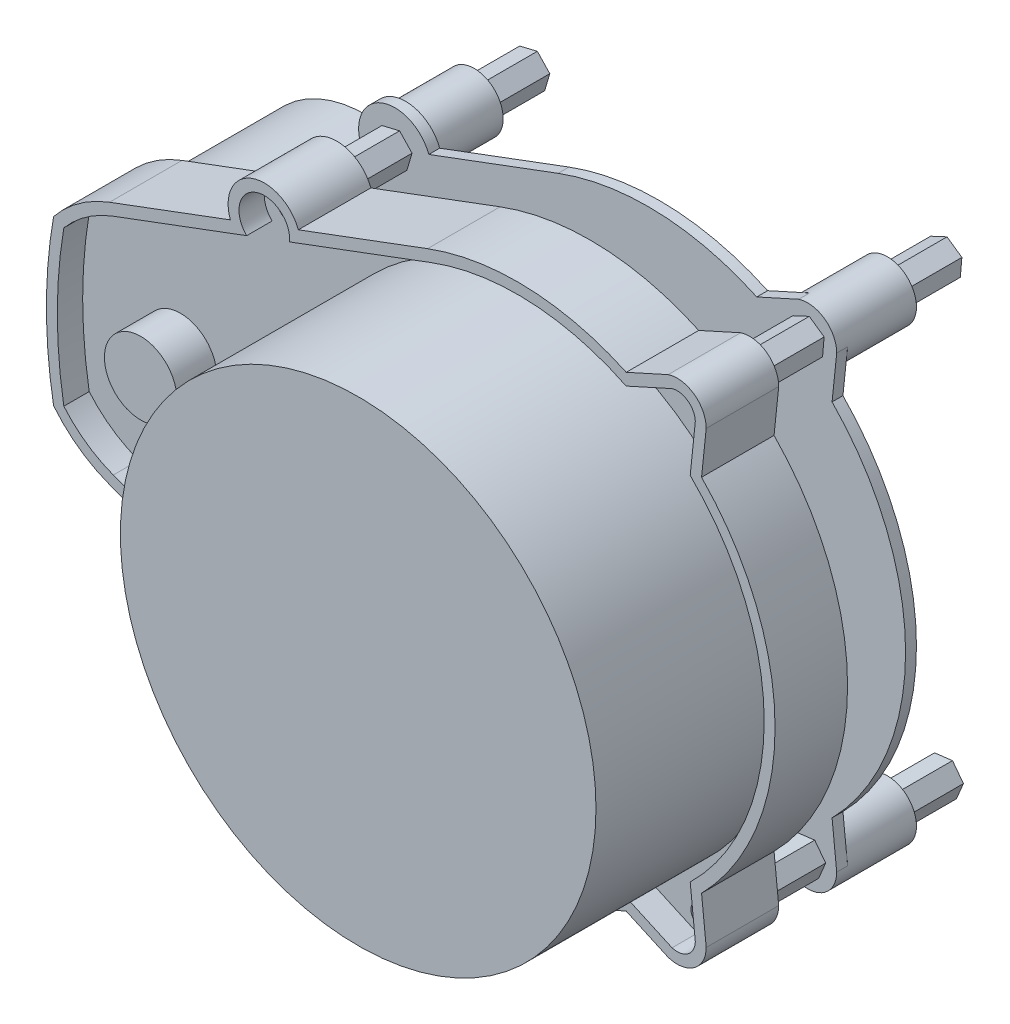
from build123d import *

# Parameters (mm, degrees)
ESQUISSE1_R             = 1.6
BOSS_EXTRU_1_DEPTH      = 10
ESQUISSE2_R             = 32.8
BOSS_EXTRU_2_DEPTH      = 22
ENL_V_MAT_EXTRU_1_DEPTH = 3.5
BOSS_EXTRU_3_REACH      = 12
ESQUISSE4_R             = 32.8
ESQUISSE5_R             = 16
BOSS_EXTRU_4_DEPTH      = 19
ESQUISSE6_R             = 1
BOSS_EXTRU_5_DEPTH      = 27
BOSS_EXTRU_6_DEPTH      = 1.5
ESQUISSE8_R             = 5
BOSS_EXTRU_7_DEPTH      = 5.5
SKETCH2_R               = 4
SKETCH2_R_2             = 3
BOSS_EXTRUDE1_DEPTH     = 9.5


with BuildPart() as part:
    # Esquisse1 → Boss.-Extru.1 (new body)
    with BuildSketch(Plane.XY):
        with BuildLine():
            ThreePointArc((-56.3, -16.861494596), (-60.528670487, -14.599558136), (-64.01, -11.301322931))
            ThreePointArc((-64.01, -11.301322931), (-65, 0), (-64.01, 11.301322931))
            ThreePointArc((-64.01, 11.301322931), (-60.528670487, 14.599558136), (-56.3, 16.861494596))
            Line((-56.3, 16.861494596), (-39.624688626, 23.091930519))
            ThreePointArc((-39.624688626, 23.091930519), (-36.690940127, 29.525679018), (-30.257191628, 26.591930519))
            Line((-30.257191628, 26.591930519), (-12.425, 33.254614341))
            ThreePointArc((-12.425, 33.254614341), (1.381675102, 35.473102119), (14.973963383, 32.187426436))
            Line((14.973963383, 32.187426436), (20.756023105, 34.801647207))
            ThreePointArc((20.756023105, 34.801647207), (24.347774736, 34.238511045), (26, 31))
            Line((26, 31), (25.359978077, 24.841930519))
            ThreePointArc((25.359978077, 24.841930519), (35.5, 0), (25.359978077, -24.841930519))
            Line((25.359978077, -24.841930519), (26, -31))
            ThreePointArc((26, -31), (24.347774736, -34.238511045), (20.756023105, -34.801647207))
            Line((20.756023105, -34.801647207), (14.973963383, -32.187426436))
            ThreePointArc((14.973963383, -32.187426436), (1.381675102, -35.473102119), (-12.425, -33.254614341))
            Line((-12.425, -33.254614341), (-30.257191628, -26.591930519))
            ThreePointArc((-30.257191628, -26.591930519), (-36.690940127, -29.525679018), (-39.624688626, -23.091930519))
            Line((-39.624688626, -23.091930519), (-56.3, -16.861494596))
        make_face()
        with Locations((-35, -25)):
            Circle(ESQUISSE1_R, mode=Mode.SUBTRACT)
        with Locations((22, 31)):
            Circle(ESQUISSE1_R, mode=Mode.SUBTRACT)
        with Locations((-35, 25)):
            Circle(ESQUISSE1_R, mode=Mode.SUBTRACT)
        with Locations((22, -31)):
            Circle(ESQUISSE1_R, mode=Mode.SUBTRACT)
    extrude(amount=BOSS_EXTRU_1_DEPTH)

    # Esquisse2 → Boss.-Extru.2 (add)
    with BuildSketch(Plane.XY.offset(10)):
        Circle(ESQUISSE2_R)
    extrude(amount=BOSS_EXTRU_2_DEPTH)

    # Esquisse3 → Enlèv. mat.-Extru.1 (cut)
    with BuildSketch(Plane.XY.offset(10)):
        with BuildLine():
            Line((-55.775, -15.456370046), (-37.378202776, -22.330008789))
            ThreePointArc((-37.378202776, -22.330008789), (-36.165940127, -28.120554469), (-31.453677478, -24.543603151))
            Line((-31.453677478, -24.543603151), (-11.9, -31.849489792))
            ThreePointArc((-11.9, -31.849489792), (1.664031028, -33.959255009), (14.956816294, -30.533484019))
            Line((14.956816294, -30.533484019), (21.291141631, -33.397398551))
            ThreePointArc((21.291141631, -33.397398551), (23.468656713, -33.023128137), (24.499056843, -31.06866508))
            Line((24.499056843, -31.06866508), (23.79417774, -24.286562245))
            ThreePointArc((23.79417774, -24.286562245), (34, 0), (23.79417774, 24.286562245))
            Line((23.79417774, 24.286562245), (24.499056843, 31.06866508))
            ThreePointArc((24.499056843, 31.06866508), (23.468656713, 33.023128137), (21.291141631, 33.397398551))
            Line((21.291141631, 33.397398551), (14.956816294, 30.533484019))
            ThreePointArc((14.956816294, 30.533484019), (1.664031028, 33.959255009), (-11.9, 31.849489792))
            Line((-11.9, 31.849489792), (-31.453677478, 24.543603151))
            ThreePointArc((-31.453677478, 24.543603151), (-36.165940127, 28.120554469), (-37.378202776, 22.330008789))
            Line((-37.378202776, 22.330008789), (-55.775, 15.456370046))
            ThreePointArc((-55.775, 15.456370046), (-59.496201473, 13.493411636), (-62.6, 10.653168543))
            ThreePointArc((-62.6, 10.653168543), (-63.5, 0), (-62.6, -10.653168543))
            ThreePointArc((-62.6, -10.653168543), (-59.496201473, -13.493411636), (-55.775, -15.456370046))
        make_face()
    extrude(amount=-ENL_V_MAT_EXTRU_1_DEPTH, mode=Mode.SUBTRACT)

    # Esquisse4 → Boss.-Extru.3 (add, up to next)
    with BuildSketch(Plane(origin=(0, 0, 10), x_dir=(-1, 0, 0), z_dir=(0, 0, -1)), mode=Mode.PRIVATE) as boss_extru_3_sk1:
        Circle(ESQUISSE4_R)
    boss_extru_3_tool1 = extrude(boss_extru_3_sk1.sketch, amount=BOSS_EXTRU_3_REACH, mode=Mode.PRIVATE) - part.part
    add(boss_extru_3_tool1.solids().sort_by_distance((0, 0, 10))[0])

    # Esquisse5 → Boss.-Extru.4 (add)
    with BuildSketch(Plane(origin=(0, 0, 0), x_dir=(-1, 0, 0), z_dir=(0, 0, -1))):
        with Locations((50, 0)):
            Circle(ESQUISSE5_R)
    extrude(amount=BOSS_EXTRU_4_DEPTH)

    # Esquisse6 → Boss.-Extru.5 (add)
    with BuildSketch(Plane(origin=(0, 0, 0), x_dir=(-1, 0, 0), z_dir=(0, 0, -1))):
        Polygon((-20.489225606, -29.008126327), (-22.969626005, -28.695694159), (-24.480400399, -30.687567832), (-23.510774394, -32.991873673), (-21.030373995, -33.304305841), (-19.519599601, -31.312432168), align=None)
        with Locations((-22, -31)):
            Circle(ESQUISSE6_R, mode=Mode.SUBTRACT)
        Polygon((36.086835018, -22.748602735), (33.593650283, -22.933074633), (32.506815266, -25.184471898), (33.913164982, -27.251397265), (36.406349717, -27.066925367), (37.493184734, -24.815528102), align=None)
        with Locations((35, -25)):
            Circle(ESQUISSE6_R, mode=Mode.SUBTRACT)
        Polygon((36.720274889, 26.814016072), (34.289153443, 27.396809791), (32.568878555, 25.582793719), (33.279725111, 23.185983928), (35.710846557, 22.603190209), (37.431121445, 24.417206281), align=None)
        with Locations((35, 25)):
            Circle(ESQUISSE6_R, mode=Mode.SUBTRACT)
        Polygon((-19.952160425, 32.43399898), (-22.217959758, 33.490480585), (-24.265799333, 32.056481605), (-24.047839575, 29.56600102), (-21.782040242, 28.509519415), (-19.734200667, 29.943518395), align=None)
        with Locations((-22, 31)):
            Circle(ESQUISSE6_R, mode=Mode.SUBTRACT)
    extrude(amount=BOSS_EXTRU_5_DEPTH)

    # Esquisse7 → Boss.-Extru.6 (add)
    with BuildSketch(Plane(origin=(0, 0, -8), x_dir=(-1, 0, 0), z_dir=(0, 0, -1))):
        with BuildLine():
            Line((30.257191628, 26.591930519), (12.425, 33.254614341))
            ThreePointArc((12.425, 33.254614341), (-1.381675102, 35.473102119), (-14.973963383, 32.187426436))
            Line((-14.973963383, 32.187426436), (-20.756023105, 34.801647207))
            ThreePointArc((-20.756023105, 34.801647207), (-24.347774736, 34.238511045), (-26, 31))
            Line((-26, 31), (-25.359978077, 24.841930519))
            ThreePointArc((-25.359978077, 24.841930519), (-35.5, 0), (-25.359978077, -24.841930519))
            Line((-25.359978077, -24.841930519), (-26, -31))
            ThreePointArc((-26, -31), (-24.347774736, -34.238511045), (-20.756023105, -34.801647207))
            Line((-20.756023105, -34.801647207), (-14.973963383, -32.187426436))
            ThreePointArc((-14.973963383, -32.187426436), (-1.381675102, -35.473102119), (12.425, -33.254614341))
            Line((12.425, -33.254614341), (30.257191628, -26.591930519))
            ThreePointArc((30.257191628, -26.591930519), (36.690940127, -29.525679018), (39.624688626, -23.091930519))
            ThreePointArc((39.624688626, -23.091930519), (33.487603548, 0), (39.624688626, 23.091930519))
            ThreePointArc((39.624688626, 23.091930519), (36.690940127, 29.525679018), (30.257191628, 26.591930519))
        make_face()
    extrude(amount=BOSS_EXTRU_6_DEPTH)

    # Esquisse8 → Boss.-Extru.7 (add)
    with BuildSketch(Plane.XY.offset(6.5)):
        with Locations((-50, 0)):
            Circle(ESQUISSE8_R)
    extrude(amount=BOSS_EXTRU_7_DEPTH)

    # Sketch2 → Boss-Extrude1 (add)
    with BuildSketch(Plane(origin=(0, 0, -9.5), x_dir=(-1, 0, 0), z_dir=(0, 0, -1))):
        with Locations((-22, 31)):
            Circle(SKETCH2_R)
        with Locations((-22, 31)):
            Circle(SKETCH2_R_2, mode=Mode.SUBTRACT)
        with Locations((35, 25)):
            Circle(SKETCH2_R)
        with Locations((35, 25)):
            Circle(SKETCH2_R_2, mode=Mode.SUBTRACT)
        with Locations((-22, -31)):
            Circle(SKETCH2_R)
        with Locations((-22, -31)):
            Circle(SKETCH2_R_2, mode=Mode.SUBTRACT)
        with Locations((35, -25)):
            Circle(SKETCH2_R)
        with Locations((35, -25)):
            Circle(SKETCH2_R_2, mode=Mode.SUBTRACT)
    extrude(amount=BOSS_EXTRUDE1_DEPTH)


solid = part.part
